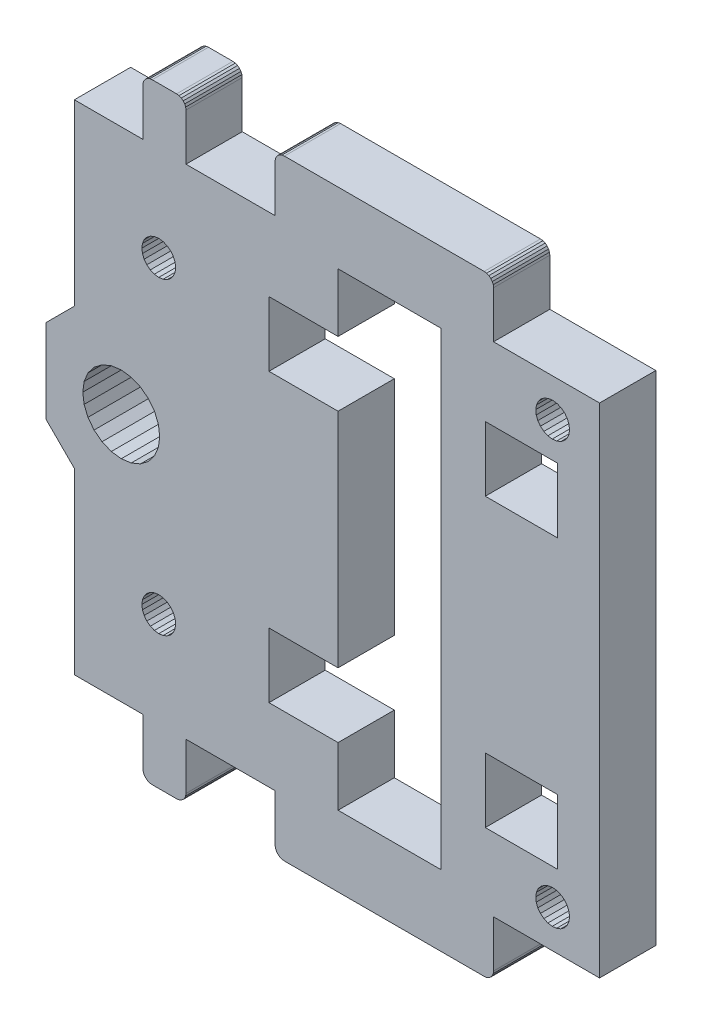
from build123d import *

# Parameters (mm, degrees)
SKETCH1_W           = 7.7
SKETCH1_H           = 6.9
BOSS_EXTRUDE1_DEPTH = 6


with BuildPart() as part:
    # Sketch1 → Boss-Extrude1 (new body)
    with BuildSketch(Plane.XY):
        Polygon((-425.725910347, -95.913150874), (-425.825810769, -96.154331829), (-425.859884943, -96.413150874), (-425.859884943, -101.413150874), (-435.358462039, -101.413150874), (-435.358462039, -96.413150874), (-435.392536213, -96.154331829), (-435.492436635, -95.913150874), (-435.651355258, -95.706044093), (-435.858462039, -95.54712547), (-436.099642994, -95.447225048), (-436.358462039, -95.413150874), (-438.958154824, -95.413150874), (-439.216973869, -95.447225048), (-439.458154824, -95.54712547), (-439.665261605, -95.706044093), (-439.824180228, -95.913150874), (-439.924080651, -96.154331829), (-439.958154824, -96.413150874), (-439.958154824, -101.413150874), (-447.259884943, -101.413150874), (-447.259884943, -120.474064779), (-450.259884943, -123.474064779), (-450.259884943, -127.935104191), (-450.263577359, -127.963150874), (-450.259884943, -127.991197556), (-450.259884943, -132.452236968), (-447.259884943, -135.452236968), (-447.259884943, -154.513150874), (-439.958154824, -154.513150874), (-439.954220965, -159.513937522), (-439.919977227, -159.772603066), (-439.819984343, -160.013604976), (-439.661049879, -160.220535722), (-439.453994171, -160.379307356), (-439.212913676, -160.479110625), (-438.954221274, -160.513150874), (-436.359884943, -160.513150874), (-436.101065898, -160.4790767), (-435.859884943, -160.379176278), (-435.652778162, -160.220257655), (-435.493859539, -160.013150874), (-435.393959117, -159.771969919), (-435.359884943, -159.513150874), (-435.359884943, -154.513150874), (-425.859884943, -154.513150874), (-425.859884943, -159.513150874), (-425.825810769, -159.771969919), (-425.725910347, -160.013150874), (-425.566991724, -160.220257655), (-425.359884943, -160.379176278), (-425.118703988, -160.4790767), (-424.859884943, -160.513150874), (-403.559884943, -160.513150874), (-403.301065898, -160.4790767), (-403.059884943, -160.379176278), (-402.852778162, -160.220257655), (-402.693859539, -160.013150874), (-402.593959117, -159.771969919), (-402.559884943, -159.513150874), (-402.559884943, -154.513150874), (-391.259884943, -154.513150874), (-391.259884943, -101.413150874), (-402.559884943, -101.413150874), (-402.559884943, -96.413150874), (-402.593959117, -96.154331829), (-402.693859539, -95.913150874), (-402.852778162, -95.706044093), (-403.059884943, -95.54712547), (-403.301065898, -95.447225048), (-403.559884943, -95.413150874), (-424.859884943, -95.413150874), (-425.118703988, -95.447225048), (-425.359884943, -95.54712547), (-425.566991724, -95.706044093), align=None)
        Polygon((-397.798040043, -104.528229012), (-397.987604263, -104.958189536), (-398.059427266, -105.422562341), (-398.008614433, -105.889701187), (-397.838628576, -106.327771335), (-397.561053949, -106.706919026), (-397.194806805, -107.001305974), (-396.764846281, -107.190870193), (-396.300473476, -107.262693196), (-395.83333463, -107.211880364), (-395.395264482, -107.041894507), (-395.016116791, -106.76431988), (-394.721729843, -106.398072736), (-394.532165623, -105.968112211), (-394.46034262, -105.503739407), (-394.511155453, -105.03660056), (-394.68114131, -104.598530413), (-394.958715937, -104.219382721), (-395.324963081, -103.924995774), (-395.754923605, -103.735431554), (-396.21929641, -103.663608551), (-396.686435257, -103.714421384), (-397.124505404, -103.884407241), (-397.503653096, -104.161981868), align=None, mode=Mode.SUBTRACT)
        Polygon((-446.359884943, -127.963150874), (-446.220180831, -129.024308959), (-445.810589099, -130.013150874), (-445.159022746, -130.862288677), (-444.309884943, -131.513855029), (-443.321043028, -131.923446762), (-442.259884943, -132.063150874), (-441.198726858, -131.923446762), (-440.209884943, -131.513855029), (-439.36074714, -130.862288677), (-438.709180788, -130.013150874), (-438.299589055, -129.024308959), (-438.159884943, -127.963150874), (-438.299589055, -126.901992789), (-438.709180788, -125.913150874), (-439.36074714, -125.064013071), (-440.209884943, -124.412446718), (-441.198726858, -124.002854986), (-442.259884943, -123.863150874), (-443.321043028, -124.002854986), (-444.309884943, -124.412446718), (-445.159022746, -125.064013071), (-445.810589099, -125.913150874), (-446.220180831, -126.901992789), align=None, mode=Mode.SUBTRACT)
        Polygon((-395.020406181, -151.768406557), (-394.724815366, -151.403130339), (-394.533837006, -150.973796073), (-394.460485961, -150.509662181), (-394.509760982, -150.04235862), (-394.678304059, -149.603731356), (-394.95462926, -149.223672112), (-395.319905478, -148.928081297), (-395.749239744, -148.737102937), (-396.213373636, -148.663751891), (-396.680677197, -148.713026913), (-397.119304461, -148.88156999), (-397.499363705, -149.15789519), (-397.79495452, -149.523171409), (-397.98593288, -149.952505674), (-398.059283926, -150.416639566), (-398.010008904, -150.883943127), (-397.841465827, -151.322570391), (-397.565140627, -151.702629636), (-397.199864408, -151.998220451), (-396.770530143, -152.189198811), (-396.306396251, -152.262549856), (-395.83909269, -152.213274835), (-395.400465426, -152.044731758), align=None, mode=Mode.SUBTRACT)
        Polygon((-439.99855143, -111.047276593), (-440.059884943, -111.513150874), (-439.99855143, -111.979025155), (-439.81873067, -112.413150874), (-439.532677149, -112.78594308), (-439.159884943, -113.071996601), (-438.725759224, -113.251817361), (-438.259884943, -113.313150874), (-437.794010662, -113.251817361), (-437.359884943, -113.071996601), (-436.987092737, -112.78594308), (-436.701039216, -112.413150874), (-436.521218456, -111.979025155), (-436.459884943, -111.513150874), (-436.521218456, -111.047276593), (-436.701039216, -110.613150874), (-436.987092737, -110.240358668), (-437.359884943, -109.954305147), (-437.794010662, -109.774484386), (-438.259884943, -109.713150874), (-438.725759224, -109.774484386), (-439.159884943, -109.954305147), (-439.532677149, -110.240358668), (-439.81873067, -110.613150874), align=None, mode=Mode.SUBTRACT)
        Polygon((-419.142418856, -139.813150874), (-419.142418856, -116.113150874), (-426.510883014, -116.113150874), (-426.510883014, -109.213150874), (-419.142418856, -109.213150874), (-419.142418856, -102.963161025), (-408.142423852, -102.963161025), (-408.142423852, -152.963140723), (-419.142418856, -152.963140723), (-419.142418856, -146.713150874), (-426.510883014, -146.713150874), (-426.510883014, -139.813150874), align=None, mode=Mode.SUBTRACT)
        with Locations((-399.592423852, -112.663150874)):
            Rectangle(SKETCH1_W, SKETCH1_H, mode=Mode.SUBTRACT)
        with Locations((-399.592423852, -143.263150874)):
            Rectangle(SKETCH1_W, SKETCH1_H, mode=Mode.SUBTRACT)
        Polygon((-438.725759224, -146.151817361), (-438.259884943, -146.213150874), (-437.794010662, -146.151817361), (-437.359884943, -145.971996601), (-436.987092737, -145.68594308), (-436.701039216, -145.313150874), (-436.521218456, -144.879025155), (-436.459884943, -144.413150874), (-436.521218456, -143.947276593), (-436.701039216, -143.513150874), (-436.987092737, -143.140358668), (-437.359884943, -142.854305147), (-437.794010662, -142.674484386), (-438.259884943, -142.613150874), (-438.725759224, -142.674484386), (-439.159884943, -142.854305147), (-439.532677149, -143.140358668), (-439.81873067, -143.513150874), (-439.99855143, -143.947276593), (-440.059884943, -144.413150874), (-439.99855143, -144.879025155), (-439.81873067, -145.313150874), (-439.532677149, -145.68594308), (-439.159884943, -145.971996601), align=None, mode=Mode.SUBTRACT)
    extrude(amount=BOSS_EXTRUDE1_DEPTH)


solid = part.part
